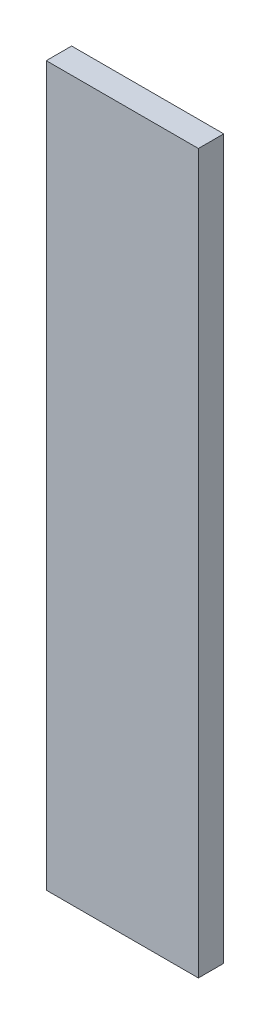
from build123d import *

# Parameters (mm, degrees)
ESBO_O1_W                = 18
ESBO_O1_H                = 85
RESSALTO_EXTRUS_O1_DEPTH = 3


with BuildPart() as part:
    # Esboço1 → Ressalto-extrusão1 (new body)
    with BuildSketch(Plane.XY):
        with Locations((1.265625, -34.73046875)):
            Rectangle(ESBO_O1_W, ESBO_O1_H)
    extrude(amount=RESSALTO_EXTRUS_O1_DEPTH)


solid = part.part
